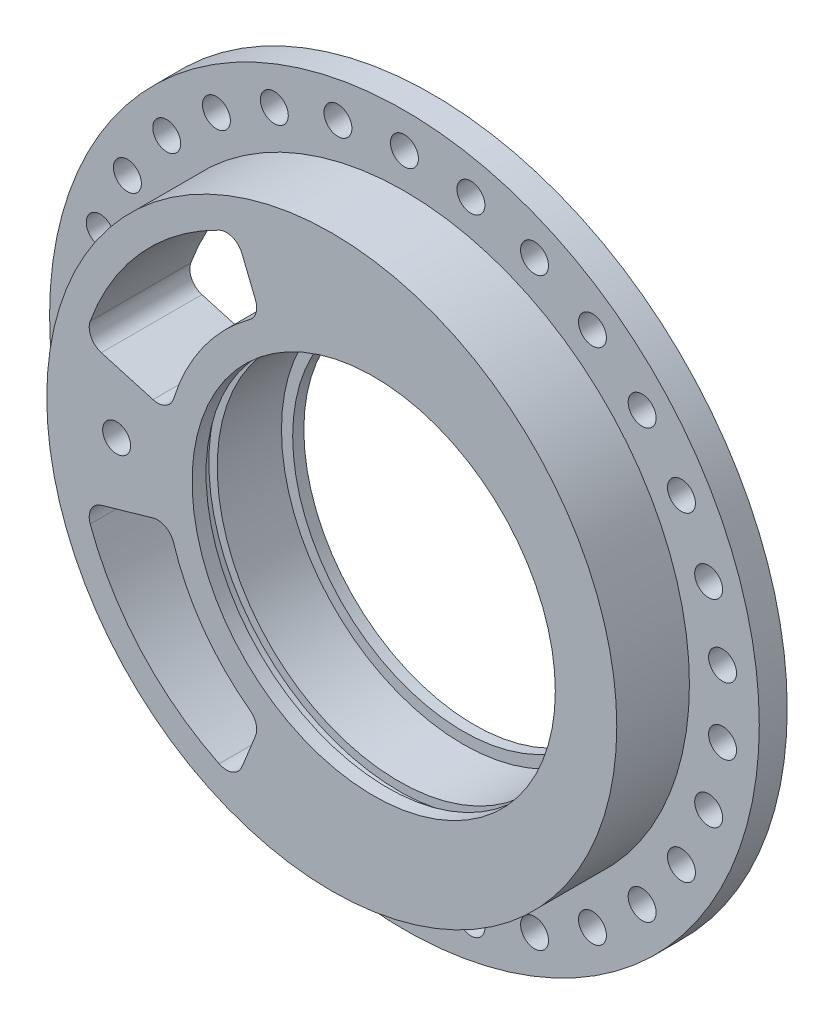
from build123d import *

# Parameters (mm, degrees)
SKETCH1_R           = 63.5
BOSS_EXTRUDE1_DEPTH = 5
SKETCH2_R           = 51
BOSS_EXTRUDE2_DEPTH = 13
SKETCH3_R           = 32.5
CUT_EXTRUDE1_DEPTH  = 19
CUT_EXTRUDE9_START  = -2.5
SKETCH4_R           = 34
SKETCH4_R_2         = 32.5
CUT_EXTRUDE9_DEPTH  = 2
SKETCH6_R           = 32.5
SKETCH6_R_2         = 30.5
BOSS_EXTRUDE3_DEPTH = 2
SKETCH7_R           = 2.5
CUT_EXTRUDE10_DEPTH = 19
SKETCH9_R           = 2.5
CUT_EXTRUDE11_DEPTH = 19
CUT_EXTRUDE12_DEPTH = 19
FILLET1_R           = 3


with BuildPart() as part:
    # Sketch1 → Boss-Extrude1 (new body)
    with BuildSketch(Plane.XY):
        Circle(SKETCH1_R)
    extrude(amount=BOSS_EXTRUDE1_DEPTH)

    # Sketch2 → Boss-Extrude2 (add)
    with BuildSketch(Plane.XY.offset(5)):
        Circle(SKETCH2_R)
    extrude(amount=BOSS_EXTRUDE2_DEPTH)

    # Sketch3 → Cut-Extrude1 (cut, through all)
    with BuildSketch(Plane.XY.offset(18)):
        with Locations((7.5, 0)):
            Circle(SKETCH3_R)
    extrude(amount=-CUT_EXTRUDE1_DEPTH, mode=Mode.SUBTRACT)

    # Sketch4 → Cut-Extrude9 (cut)
    with BuildSketch(Plane.XY.offset(18).offset(CUT_EXTRUDE9_START)):
        with Locations((7.5, 0)):
            Circle(SKETCH4_R)
        with Locations((7.5, 0)):
            Circle(SKETCH4_R_2, mode=Mode.SUBTRACT)
    extrude(amount=-CUT_EXTRUDE9_DEPTH, mode=Mode.SUBTRACT)

    # Sketch6 → Boss-Extrude3 (add)
    with BuildSketch(Plane(origin=(0, 0, 0), x_dir=(-1, 0, 0), z_dir=(0, 0, -1))):
        with Locations((-7.5, 0)):
            Circle(SKETCH6_R)
        with Locations((-7.5, 0)):
            Circle(SKETCH6_R_2, mode=Mode.SUBTRACT)
    extrude(amount=-BOSS_EXTRUDE3_DEPTH)

    # Sketch7 → Cut-Extrude10 (cut, through all)
    with BuildSketch(Plane.XY.offset(18)):
        with Locations((0, 57.24)):
            Circle(SKETCH7_R)
        with Locations((11.900865182, 55.989168666)):
            Circle(SKETCH7_R)
        with Locations((23.28160545, 52.291341995)):
            Circle(SKETCH7_R)
        with Locations((33.644827841, 46.308132758)):
            Circle(SKETCH7_R)
        with Locations((42.53760981, 38.301035908)):
            Circle(SKETCH7_R)
        with Locations((49.571294113, 28.62)):
            Circle(SKETCH7_R)
        with Locations((54.438474993, 17.688132758)):
            Circle(SKETCH7_R)
        with Locations((56.926433291, 5.983209237)):
            Circle(SKETCH7_R)
        with Locations((56.926433291, -5.983209237)):
            Circle(SKETCH7_R)
        with Locations((54.438474993, -17.688132758)):
            Circle(SKETCH7_R)
        with Locations((49.571294113, -28.62)):
            Circle(SKETCH7_R)
        with Locations((42.53760981, -38.301035908)):
            Circle(SKETCH7_R)
        with Locations((33.644827841, -46.308132758)):
            Circle(SKETCH7_R)
        with Locations((23.28160545, -52.291341995)):
            Circle(SKETCH7_R)
        with Locations((11.900865182, -55.989168666)):
            Circle(SKETCH7_R)
        with Locations((0, -57.24)):
            Circle(SKETCH7_R)
        with Locations((-11.900865182, -55.989168666)):
            Circle(SKETCH7_R)
        with Locations((-23.28160545, -52.291341995)):
            Circle(SKETCH7_R)
        with Locations((-33.644827841, -46.308132758)):
            Circle(SKETCH7_R)
        with Locations((-42.53760981, -38.301035908)):
            Circle(SKETCH7_R)
        with Locations((-49.571294113, -28.62)):
            Circle(SKETCH7_R)
        with Locations((-54.438474993, -17.688132758)):
            Circle(SKETCH7_R)
        with Locations((-56.926433291, -5.983209237)):
            Circle(SKETCH7_R)
        with Locations((-56.926433291, 5.983209237)):
            Circle(SKETCH7_R)
        with Locations((-54.438474993, 17.688132758)):
            Circle(SKETCH7_R)
        with Locations((-49.571294113, 28.62)):
            Circle(SKETCH7_R)
        with Locations((-42.53760981, 38.301035908)):
            Circle(SKETCH7_R)
        with Locations((-33.644827841, 46.308132758)):
            Circle(SKETCH7_R)
        with Locations((-23.28160545, 52.291341995)):
            Circle(SKETCH7_R)
        with Locations((-11.900865182, 55.989168666)):
            Circle(SKETCH7_R)
    extrude(amount=-CUT_EXTRUDE10_DEPTH, mode=Mode.SUBTRACT)

    # Sketch9 → Cut-Extrude11 (cut, through all)
    with BuildSketch(Plane.XY.offset(18)):
        with Locations((-38.5, 0)):
            Circle(SKETCH9_R)
    extrude(amount=-CUT_EXTRUDE11_DEPTH, mode=Mode.SUBTRACT)

    # Sketch10 → Cut-Extrude12 (cut, through all)
    with BuildSketch(Plane.XY.offset(18)):
        with BuildLine():
            Line((-12.751630161, 31.561392172), (-17.231903297, 42.65045731))
            ThreePointArc((-17.231903297, 42.65045731), (-34.184661972, 30.780007893), (-44.218038013, 12.679318368))
            Line((-44.218038013, 12.679318368), (-29.062316979, 8.333485293))
            ThreePointArc((-29.062316979, 8.333485293), (-23.189412863, 21.550172577), (-12.751630161, 31.561392172))
        make_face()
        with BuildLine():
            Line((-12.751630161, -31.561392172), (-17.231903297, -42.65045731))
            ThreePointArc((-17.231903297, -42.65045731), (-34.184661972, -30.780007893), (-44.218038013, -12.679318368))
            Line((-44.218038013, -12.679318368), (-29.062316979, -8.333485293))
            ThreePointArc((-29.062316979, -8.333485293), (-23.189412863, -21.550172577), (-12.751630161, -31.561392172))
        make_face()
    extrude(amount=-CUT_EXTRUDE12_DEPTH, mode=Mode.SUBTRACT)

    # Fillet1
    fillet1_edges = [part.edges().sort_by_distance(p)[0] for p in [
        (-12.751630161, 31.561392172, 9),
        (-29.062316979, 8.333485293, 9),
        (-44.218038013, 12.679318368, 9),
        (-17.231903297, 42.65045731, 9),
        (-29.062316979, -8.333485293, 9),
        (-12.751630161, -31.561392172, 9),
        (-17.231903297, -42.65045731, 9),
        (-44.218038013, -12.679318368, 9),
    ]]
    fillet(fillet1_edges, radius=FILLET1_R)


solid = part.part
